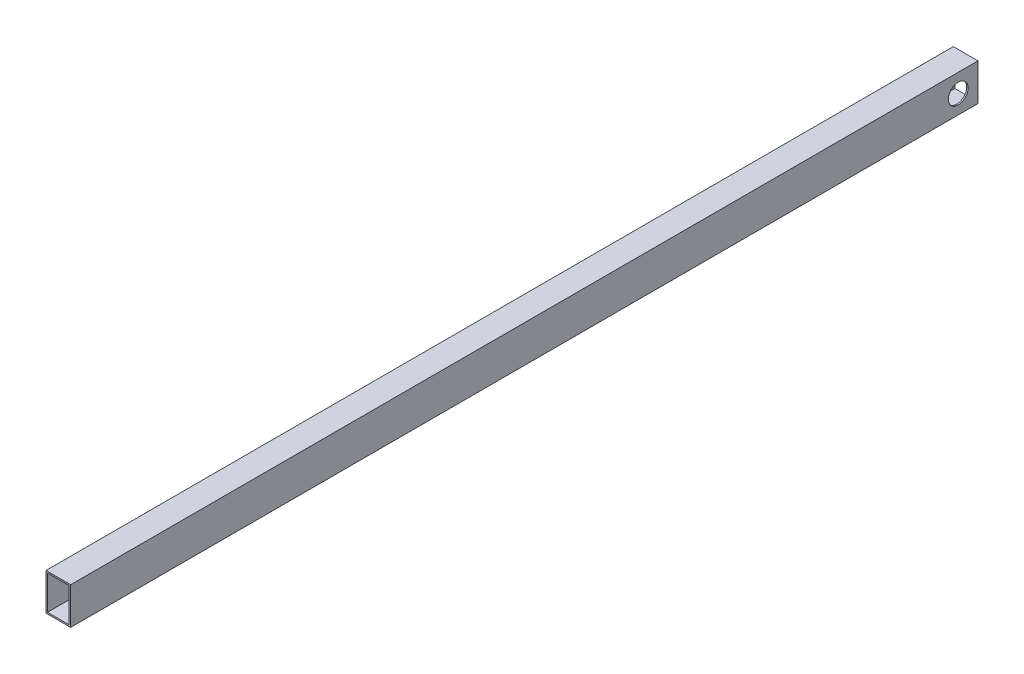
from build123d import *

# Parameters (mm, degrees)
SKETCH1_W                = 100
SKETCH1_H                = 150
SKETCH1_W_2              = 88
SKETCH1_H_2              = 138
BOSS_EXTRUDE1_DEPTH      = 3600
BOSS_EXTRUDE1_DEPTH_BACK = 80
SKETCH2_R                = 40
CUT_EXTRUDE1_DEPTH       = 51
CUT_EXTRUDE1_DEPTH_BACK  = 51


with BuildPart() as part:
    # Sketch1 → Boss-Extrude1 (new body, two sides)
    with BuildSketch(Plane.XY) as boss_extrude1_sk:
        Rectangle(SKETCH1_W, SKETCH1_H)
        Rectangle(SKETCH1_W_2, SKETCH1_H_2, mode=Mode.SUBTRACT)
    extrude(amount=BOSS_EXTRUDE1_DEPTH)
    extrude(boss_extrude1_sk.sketch, amount=-BOSS_EXTRUDE1_DEPTH_BACK)

    # Sketch2 → Cut-Extrude1 (cut, two sides)
    with BuildSketch(Plane(origin=(0, 0, 0), x_dir=(0, 0, -1), z_dir=(1, 0, 0))) as cut_extrude1_sk:
        Circle(SKETCH2_R)
    extrude(amount=CUT_EXTRUDE1_DEPTH, mode=Mode.SUBTRACT)
    extrude(cut_extrude1_sk.sketch, amount=-CUT_EXTRUDE1_DEPTH_BACK, mode=Mode.SUBTRACT)


solid = part.part
